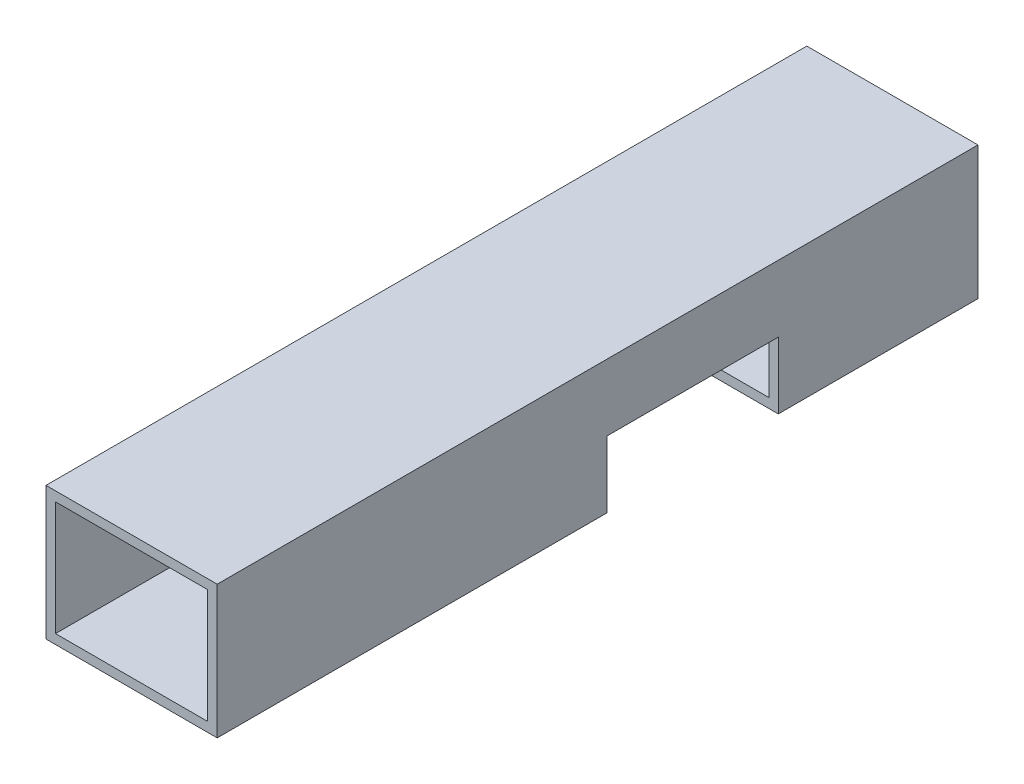
from build123d import *

# Parameters (mm, degrees)
ESQUISSE1_W             = 9
ESQUISSE1_H             = 7
ESQUISSE1_W_2           = 8
ESQUISSE1_H_2           = 6
BOSS_EXTRU_1_DEPTH      = 40
ESQUISSE4_W             = 9
ESQUISSE4_H             = 3.5
ENL_V_MAT_EXTRU_1_DEPTH = 50


with BuildPart() as part:
    # Esquisse1 → Boss.-Extru.1 (new body)
    with BuildSketch(Plane.XY):
        with Locations((4.5, 3.5)):
            Rectangle(ESQUISSE1_W, ESQUISSE1_H)
        with Locations((4.5, 3.5)):
            Rectangle(ESQUISSE1_W_2, ESQUISSE1_H_2, mode=Mode.SUBTRACT)
    extrude(amount=BOSS_EXTRU_1_DEPTH)

    # Esquisse4 → Enlèv. mat.-Extru.1 (cut)
    with BuildSketch(Plane(origin=(9, 0, 0), x_dir=(0, 0, -1), z_dir=(1, 0, 0))):
        with Locations((-15, 1.75)):
            Rectangle(ESQUISSE4_W, ESQUISSE4_H)
    extrude(amount=-ENL_V_MAT_EXTRU_1_DEPTH, mode=Mode.SUBTRACT)


solid = part.part
